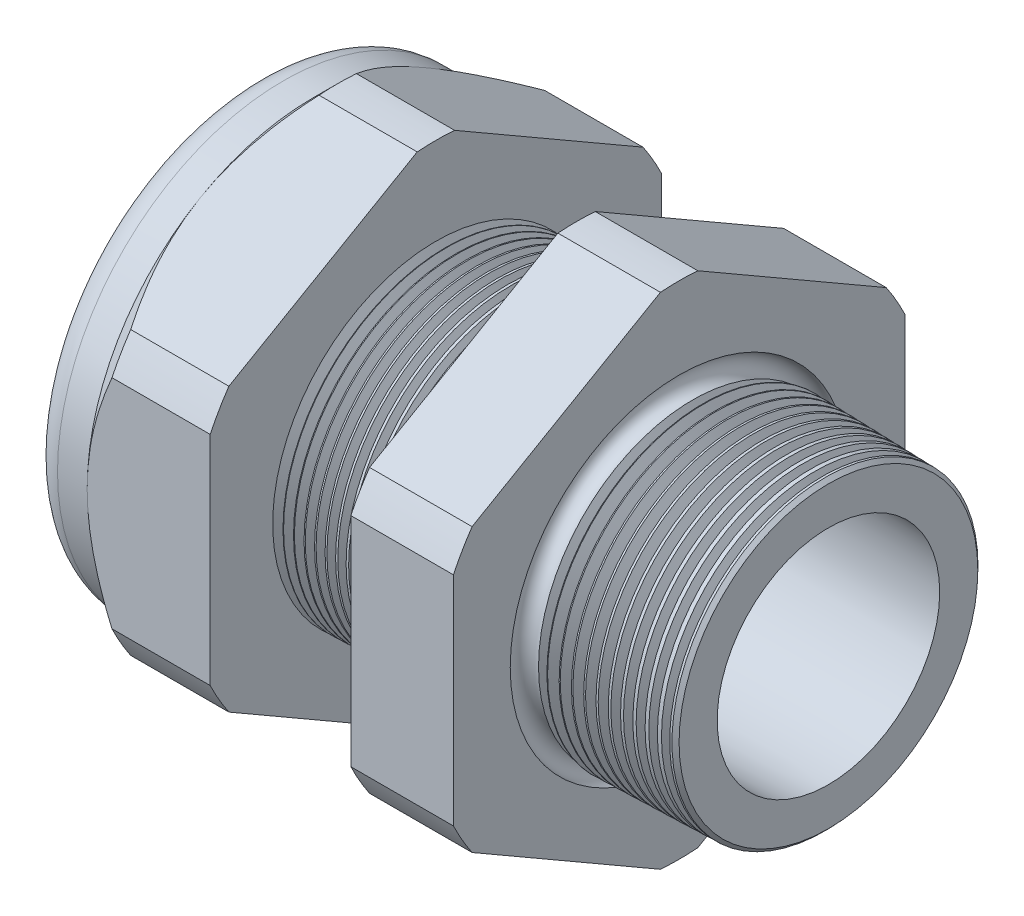
from build123d import *

# Parameters (mm, degrees)
SKETCH12_OUTSIDE_W = 88.514
SKETCH12_OUTSIDE_H = 88.514
CUT_EXTRUDE2_DEPTH = 38.71
FILLET4_R          = 2.032
SKETCH19_OUTSIDE_W = 55.962
SKETCH19_OUTSIDE_H = 59.594
SKETCH19_OUTSIDE_R = 16.51
CUT_EXTRUDE3_DEPTH = 3.99796
CUT_EXTRUDE3_DRAFT = -45
CHAMFER1_SIZE      = 0.260919487
CHAMFER1_SIZE2     = 0.254
SKETCH21_R         = 9.017
PLUG_DEPTH         = 8.89
SKETCH22_R         = 8.763
CUT_EXTRUDE4_DEPTH = 0.508
SKETCH27_R         = 3.048
PLUGHOLES_DEPTH    = 42.402
CIRPATTERN1_COUNT  = 4
LPATTERN1_COUNT    = 14
LPATTERN1_PITCH    = 0.762
LPATTERN2_COUNT    = 12
LPATTERN2_PITCH    = 0.889
SKETCH32_R         = 0.889


with BuildPart() as part:
    # Sketch10 → Revolve2 (revolve)
    with BuildSketch(Plane.XY, mode=Mode.PRIVATE) as revolve2_sk:
        Polygon((-38.862, 9.017), (-25.662, 9.017), (3.048, 8.138202192), (3.048, 11.186202192), (-7.874, 11.472204827), (-7.874, 33.02), (-15.374, 33.02), (-15.374, 11.668599239), (-25.662, 11.938), (-25.662, 33.02), (-34.662, 33.02), (-34.662, 16.51), (-38.862, 16.51), align=None)
    revolve(revolve2_sk.sketch.rotate(Axis((0, 0, 0), (-1, 0, 0)), 90), axis=Axis((0, 0, 0), (-1, 0, 0)))  # turned: the seam where the file's is

    # Sketch12 outside → Cut-Extrude2 (cut, through all)
    with BuildSketch(Plane.ZY.offset(34.662)):
        Rectangle(SKETCH12_OUTSIDE_W, SKETCH12_OUTSIDE_H)
        with BuildLine():
            Line((-1.366648898, 18.27507078), (-15.143351102, 10.321088053))
            ThreePointArc((-15.143351102, 10.321088053), (-15.870868152, 9.16305), (-16.51, 7.953982726))
            Line((-16.51, 7.953982726), (-16.51, -7.953982726))
            ThreePointArc((-16.51, -7.953982726), (-15.870868152, -9.16305), (-15.143351102, -10.321088053))
            Line((-15.143351102, -10.321088053), (-1.366648898, -18.27507078))
            ThreePointArc((-1.366648898, -18.27507078), (0, -18.3261), (1.366648898, -18.27507078))
            Line((1.366648898, -18.27507078), (15.143351102, -10.321088053))
            ThreePointArc((15.143351102, -10.321088053), (15.870868152, -9.16305), (16.51, -7.953982726))
            Line((16.51, -7.953982726), (16.51, 7.953982726))
            ThreePointArc((16.51, 7.953982726), (15.870868152, 9.16305), (15.143351102, 10.321088053))
            Line((15.143351102, 10.321088053), (1.366648898, 18.27507078))
            ThreePointArc((1.366648898, 18.27507078), (0, 18.3261), (-1.366648898, 18.27507078))
        make_face(mode=Mode.SUBTRACT)
    extrude(amount=-CUT_EXTRUDE2_DEPTH, mode=Mode.SUBTRACT)

    # Fillet4
    fillet4_edges = [part.edges().sort_by_distance(p)[0] for p in [
        (-38.862, 0, 16.51),
    ]]
    fillet(fillet4_edges, radius=FILLET4_R)


with BuildPart() as cut_extrude3_tool:
    # Sketch19 outside → Cut-Extrude3 (with draft: the straight prism first)
    with BuildSketch(Plane.ZY.offset(34.662)):
        Rectangle(SKETCH19_OUTSIDE_W, SKETCH19_OUTSIDE_H)
        Circle(SKETCH19_OUTSIDE_R, mode=Mode.SUBTRACT)
    extrude(amount=-CUT_EXTRUDE3_DEPTH)
    # Cut-Extrude3: the draft: its side faces are tilted about the plane it starts from
    cut_extrude3_sides = [cut_extrude3_tool.faces().sort_by_distance(p)[0] for p in [
        (-32.66302, -29.797, 0),
        (-32.66302, 0, 27.981),
        (-32.66302, 29.797, 0),
        (-32.66302, 0, -27.981),
        (-32.66302, 0, -16.51),
    ]]
    draft(cut_extrude3_sides, Plane.ZY.offset(34.662), CUT_EXTRUDE3_DRAFT)


with BuildPart() as part_1:
    add(part.part)

    # Cut-Extrude3: cut by cut_extrude3_tool
    add(cut_extrude3_tool.part, mode=Mode.SUBTRACT)

    # Chamfer1
    chamfer1_edges = [part_1.edges().sort_by_distance(p)[0] for p in [
        (3.048, 0, 11.186202192),
    ]]
    chamfer1_side = [part_1.faces().sort_by_distance(p)[0] for p in [
        (3.048, 0, 8.454595769),
    ]]
    chamfer(chamfer1_edges, length=CHAMFER1_SIZE, length2=CHAMFER1_SIZE2, reference=chamfer1_side[0])

    # Sketch29 → Cut-Revolve1 (revolve, cut)
    with BuildSketch(Plane.XY, mode=Mode.PRIVATE) as cut_revolve1_sk:
        Polygon((-25.662, 11.938), (-24.929016419, 11.918806149), (-25.312130572, 11.293620673), align=None)
    cut_revolve1 = revolve(cut_revolve1_sk.sketch.rotate(Axis((0, 0, 0), (-1, 0, 0)), 90), axis=Axis((0, 0, 0), (-1, 0, 0)), mode=Mode.SUBTRACT)  # turned: the seam where the file's is

    # LPattern1: Cut-Revolve1 ×14
    with Locations(*[(i * LPATTERN1_PITCH, 0, 0) for i in range(1, LPATTERN1_COUNT)]):
        add(cut_revolve1, mode=Mode.SUBTRACT)

    # Sketch30 → Cut-Revolve2 (revolve, cut)
    with BuildSketch(Plane.XY, mode=Mode.PRIVATE) as cut_revolve2_sk:
        Polygon((-7.874, 11.472204827), (-6.994419703, 11.449172206), (-7.454156686, 10.698949635), align=None)
    cut_revolve2 = revolve(cut_revolve2_sk.sketch.rotate(Axis((0, 0, 0), (-1, 0, 0)), 270), axis=Axis((0, 0, 0), (-1, 0, 0)), mode=Mode.SUBTRACT)  # turned: the seam where the file's is

    # LPattern2: Cut-Revolve2 ×12
    with Locations(*[(i * LPATTERN2_PITCH, 0, 0) for i in range(1, LPATTERN2_COUNT)]):
        add(cut_revolve2, mode=Mode.SUBTRACT)

    # Sketch32 → Cut-Revolve3 (revolve, cut)
    with BuildSketch(Plane.XY, mode=Mode.PRIVATE) as cut_revolve3_sk:
        with Locations((-7.747, 11.472204827)):
            Circle(SKETCH32_R)
    revolve(cut_revolve3_sk.sketch.rotate(Axis((0, 0, 0), (-1, 0, 0)), 270), axis=Axis((0, 0, 0), (-1, 0, 0)), mode=Mode.SUBTRACT)  # turned: the seam where the file's is


with BuildPart() as body_2:
    # Sketch21 → plug (new body)
    with BuildSketch(Plane.ZY.offset(38.862)):
        Circle(SKETCH21_R)
    extrude(amount=-PLUG_DEPTH)

    # Sketch22 → Cut-Extrude4 (cut)
    with BuildSketch(Plane.ZY.offset(38.862)):
        Circle(SKETCH22_R)
    extrude(amount=-CUT_EXTRUDE4_DEPTH, mode=Mode.SUBTRACT)

    # Sketch27 → plugholes (cut, through all)
    with BuildSketch(Plane.ZY.offset(38.354)):
        with Locations((-5.702808, 0)):
            Circle(SKETCH27_R)
    plugholes = extrude(amount=-PLUGHOLES_DEPTH, mode=Mode.SUBTRACT)

    # CirPattern1: plugholes ×4 about axis
    cirpattern1_axis = Axis((0, 0, 0), (1, 0, 0))
    for i in range(1, CIRPATTERN1_COUNT):
        add(plugholes.rotate(cirpattern1_axis, i * 360 / CIRPATTERN1_COUNT), mode=Mode.SUBTRACT)


solid = Compound([part_1.part, body_2.part])
